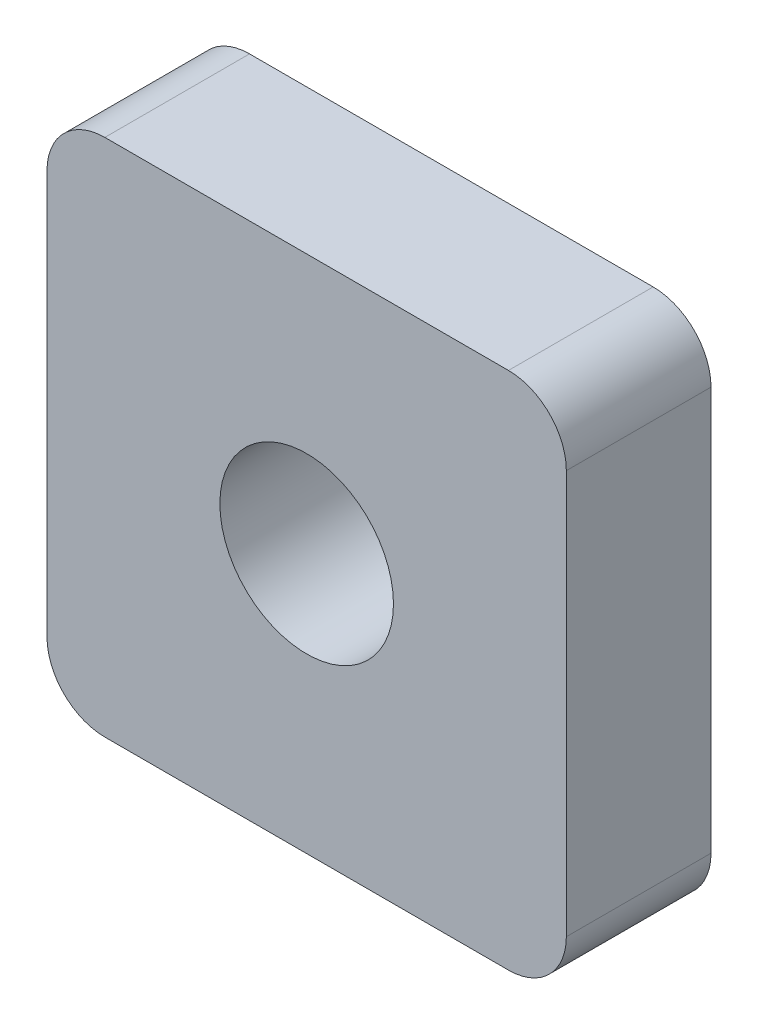
from build123d import *

# Parameters (mm, degrees)
SKETCH_1_W      = 17.95
SKETCH_1_H      = 17.95
SKETCH_1_R      = 3
EXTRUDE_1_DEPTH = 5
FILLET_1_R      = 2


with BuildPart() as part:
    # 草图1 → 凸台-拉伸1 (new body)
    with BuildSketch(Plane.XY):
        Rectangle(SKETCH_1_W, SKETCH_1_H)
        Circle(SKETCH_1_R, mode=Mode.SUBTRACT)
    extrude(amount=EXTRUDE_1_DEPTH)

    # 圆角1
    fillet_1_edges = [part.edges().sort_by_distance(p)[0] for p in [
        (8.975, -8.975, 2.5),
        (-8.975, -8.975, 2.5),
        (-8.975, 8.975, 2.5),
        (8.975, 8.975, 2.5),
    ]]
    fillet(fillet_1_edges, radius=FILLET_1_R)


solid = part.part
